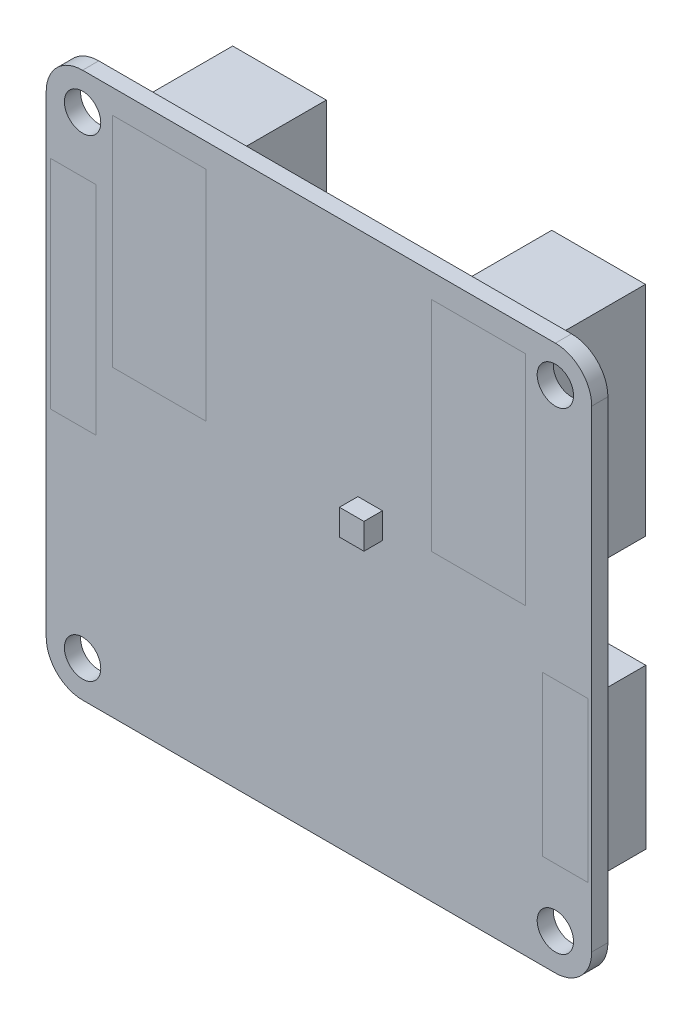
from build123d import *

# Parameters (mm, degrees)
SKETCH1_R                  = 2
SKETCH1_W                  = 5
SKETCH1_H                  = 17.526
SKETCH1_H_2                = 23.876
SKETCH1_W_2                = 10.3
SKETCH1_H_3                = 24
SKETCH1_W_3                = 2.693412003
SKETCH1_H_4                = 2.844097509
BOSS_EXTRUDE1_DEPTH        = 1.778
SKETCH1_3_W                = 10.3
SKETCH1_3_H                = 24
BOSS_EXTRUDE2_DEPTH        = 1.778
BOSS_EXTRUDE2_DEPTH_BACK   = 11.43
BOSS_EXTRUDE2_2_DEPTH      = 1.778
BOSS_EXTRUDE2_2_DEPTH_BACK = 11.43
SKETCH1_4_W                = 5
SKETCH1_4_H                = 17.526
BOSS_EXTRUDE3_DEPTH        = 1.778
BOSS_EXTRUDE3_DEPTH_BACK   = 4.572
SKETCH1_4_H_2              = 23.876
BOSS_EXTRUDE3_2_DEPTH      = 1.778
BOSS_EXTRUDE3_2_DEPTH_BACK = 4.572
SKETCH1_5_W                = 2.693412003
SKETCH1_5_H                = 2.844097509
BOSS_EXTRUDE5_DEPTH        = 3.81


with BuildPart() as part:
    # Sketch1 → Boss-Extrude1 (new body)
    with BuildSketch(Plane.XY):
        with BuildLine():
            ThreePointArc((0, 4), (1.171572875, 1.171572875), (4, 0))
            Line((4, 0), (56, 0))
            ThreePointArc((56, 0), (58.828427125, 1.171572875), (60, 4))
            Line((60, 4), (60, 56))
            ThreePointArc((60, 56), (58.828427125, 58.828427125), (56, 60))
            Line((56, 60), (4, 60))
            ThreePointArc((4, 60), (1.171572875, 58.828427125), (0, 56))
            Line((0, 56), (0, 4))
        make_face()
        with Locations((4, 4)):
            Circle(SKETCH1_R, mode=Mode.SUBTRACT)
        with Locations((56, 4)):
            Circle(SKETCH1_R, mode=Mode.SUBTRACT)
        with Locations((57.095415437, 19.177)):
            Rectangle(SKETCH1_W, SKETCH1_H, mode=Mode.SUBTRACT)
        with Locations((2.994822902, 37.902)):
            Rectangle(SKETCH1_W, SKETCH1_H_2, mode=Mode.SUBTRACT)
        with Locations((12.45, 45.35)):
            Rectangle(SKETCH1_W_2, SKETCH1_H_3, mode=Mode.SUBTRACT)
        with Locations((4, 56)):
            Circle(SKETCH1_R, mode=Mode.SUBTRACT)
        with Locations((35.630798564, 33.105263678)):
            Rectangle(SKETCH1_W_3, SKETCH1_H_4, mode=Mode.SUBTRACT)
        with Locations((47.55, 45.35)):
            Rectangle(SKETCH1_W_2, SKETCH1_H_3, mode=Mode.SUBTRACT)
        with Locations((56, 56)):
            Circle(SKETCH1_R, mode=Mode.SUBTRACT)
    extrude(amount=BOSS_EXTRUDE1_DEPTH)

    # Sketch1_5 → Boss-Extrude5 (add)
    with BuildSketch(Plane.XY):
        with Locations((35.630798564, 33.105263678)):
            Rectangle(SKETCH1_5_W, SKETCH1_5_H)
    extrude(amount=BOSS_EXTRUDE5_DEPTH)


with BuildPart() as body_2:
    # Sketch1_3 → Boss-Extrude2 (new body, two sides)
    with BuildSketch(Plane.XY) as boss_extrude2_sk:
        with Locations((47.55, 45.35)):
            Rectangle(SKETCH1_3_W, SKETCH1_3_H)
    extrude(amount=BOSS_EXTRUDE2_DEPTH)
    extrude(boss_extrude2_sk.sketch, amount=-BOSS_EXTRUDE2_DEPTH_BACK)


with BuildPart() as body_3:
    # Sketch1_3 → Boss-Extrude2 2 (new body, two sides)
    with BuildSketch(Plane.XY) as boss_extrude2_2_sk:
        with Locations((12.45, 45.35)):
            Rectangle(SKETCH1_3_W, SKETCH1_3_H)
    extrude(amount=BOSS_EXTRUDE2_2_DEPTH)
    extrude(boss_extrude2_2_sk.sketch, amount=-BOSS_EXTRUDE2_2_DEPTH_BACK)


with BuildPart() as body_4:
    # Sketch1_4 → Boss-Extrude3 (new body, two sides)
    with BuildSketch(Plane.XY) as boss_extrude3_sk:
        with Locations((57.095415437, 19.177)):
            Rectangle(SKETCH1_4_W, SKETCH1_4_H)
    extrude(amount=BOSS_EXTRUDE3_DEPTH)
    extrude(boss_extrude3_sk.sketch, amount=-BOSS_EXTRUDE3_DEPTH_BACK)


with BuildPart() as body_5:
    # Sketch1_4 → Boss-Extrude3 2 (new body, two sides)
    with BuildSketch(Plane.XY) as boss_extrude3_2_sk:
        with Locations((2.994822902, 37.902)):
            Rectangle(SKETCH1_4_W, SKETCH1_4_H_2)
    extrude(amount=BOSS_EXTRUDE3_2_DEPTH)
    extrude(boss_extrude3_2_sk.sketch, amount=-BOSS_EXTRUDE3_2_DEPTH_BACK)


solid = Compound([part.part, body_2.part, body_3.part, body_4.part, body_5.part])
